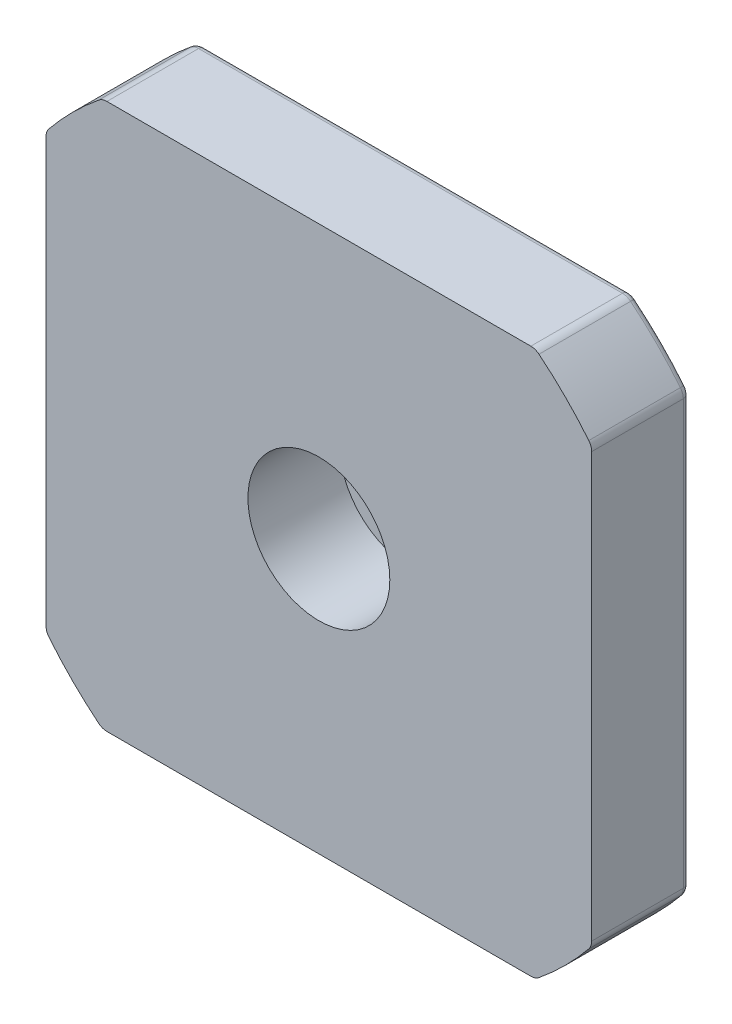
from build123d import *

# Parameters (mm, degrees)
CROQUIS1_W              = 42.3
CROQUIS1_H              = 42.3
SALIENTE_EXTRUIR1_DEPTH = 7.6
SKETCH1_R               = 29.910616844
SKETCH1_R_2             = 27
CUT_EXTRUDE1_DEPTH      = 8.6
CROQUIS3_R              = 11
CROQUIS3_R_2            = 8.5
SALIENTE_EXTRUIR2_DEPTH = 2
CROQUIS4_R              = 4.5
CORTAR_EXTRUIR2_DEPTH   = 7
CROQUIS5_R              = 2.5
CORTAR_EXTRUIR3_DEPTH   = 7
CROQUIS6_R              = 1.5
CORTAR_EXTRUIR4_DEPTH   = 4.5
SKETCH2_R               = 5.5
CUT_EXTRUDE2_DEPTH      = 7.1
SKETCH3_R               = 16.5
SKETCH3_R_2             = 11.5
CUT_EXTRUDE3_DEPTH      = 0.1
FILLET1_R               = 1
FILLET2_R               = 0.5
CHAMFER1_SIZE           = 0.5


with BuildPart() as part:
    # Croquis1 → Saliente-Extruir1 (new body)
    with BuildSketch(Plane.XY):
        Rectangle(CROQUIS1_W, CROQUIS1_H)
    extrude(amount=SALIENTE_EXTRUIR1_DEPTH)

    # Sketch1 → Cut-Extrude1 (cut, through all)
    with BuildSketch(Plane(origin=(0, 0, 0), x_dir=(-1, 0, 0), z_dir=(0, 0, -1))):
        Circle(SKETCH1_R)
        Circle(SKETCH1_R_2, mode=Mode.SUBTRACT)
    extrude(amount=-CUT_EXTRUDE1_DEPTH, mode=Mode.SUBTRACT)

    # Croquis3 → Saliente-Extruir2 (add)
    with BuildSketch(Plane(origin=(0, 0, 0), x_dir=(-1, 0, 0), z_dir=(0, 0, -1))):
        Circle(CROQUIS3_R)
        Circle(CROQUIS3_R_2, mode=Mode.SUBTRACT)
    extrude(amount=SALIENTE_EXTRUIR2_DEPTH)

    # Croquis4 → Cortar-Extruir2 (cut)
    with BuildSketch(Plane(origin=(0, 0, -2), x_dir=(-1, 0, 0), z_dir=(0, 0, -1))):
        Circle(CROQUIS4_R)
    extrude(amount=-CORTAR_EXTRUIR2_DEPTH, mode=Mode.SUBTRACT)

    # Croquis5 → Cortar-Extruir3 (cut)
    with BuildSketch(Plane(origin=(0, 0, 5), x_dir=(-1, 0, 0), z_dir=(0, 0, -1))):
        Circle(CROQUIS5_R)
    extrude(amount=-CORTAR_EXTRUIR3_DEPTH, mode=Mode.SUBTRACT)

    # Croquis6 → Cortar-Extruir4 (cut)
    with BuildSketch(Plane(origin=(0, 0, 0), x_dir=(-1, 0, 0), z_dir=(0, 0, -1))):
        with Locations((-15.5, 15.5)):
            Circle(CROQUIS6_R)
        with Locations((15.5, 15.5)):
            Circle(CROQUIS6_R)
        with Locations((15.5, -15.5)):
            Circle(CROQUIS6_R)
        with Locations((-15.5, -15.5)):
            Circle(CROQUIS6_R)
    extrude(amount=-CORTAR_EXTRUIR4_DEPTH, mode=Mode.SUBTRACT)

    # Sketch2 → Cut-Extrude2 (cut)
    with BuildSketch(Plane.XY.offset(7.6)):
        Circle(SKETCH2_R)
    extrude(amount=-CUT_EXTRUDE2_DEPTH, mode=Mode.SUBTRACT)

    # Sketch3 → Cut-Extrude3 (cut)
    with BuildSketch(Plane(origin=(0, 0, 0), x_dir=(-1, 0, 0), z_dir=(0, 0, -1))):
        Circle(SKETCH3_R)
        Circle(SKETCH3_R_2, mode=Mode.SUBTRACT)
    extrude(amount=-CUT_EXTRUDE3_DEPTH, mode=Mode.SUBTRACT)

    # Fillet1
    fillet1_edges = [part.edges().sort_by_distance(p)[0] for p in [
        (21.15, 16.783250579, 3.8),
        (21.15, -16.783250579, 3.8),
        (-16.783250579, 21.15, 3.8),
        (16.783250579, 21.15, 3.8),
        (-21.15, -16.783250579, 3.8),
        (-21.15, 16.783250579, 3.8),
        (16.783250579, -21.15, 3.8),
        (-16.783250579, -21.15, 3.8),
    ]]
    fillet(fillet1_edges, radius=FILLET1_R)

    # Fillet2
    fillet2_edges = [part.edges().sort_by_distance(p)[0] for p in [
        (19.091883092, 19.091883092, 0),
        (0, 21.15, 0),
        (-21.15, 0, 0),
        (-19.091883092, 19.091883092, 0),
        (21.15, 0, 0),
        (19.091883092, -19.091883092, 0),
        (0, -21.15, 0),
        (-19.091883092, -19.091883092, 0),
        (-16.766402254, 21.092072184, 0),
        (-21.092072184, 16.766402254, 0),
        (-21.092072184, -16.766402254, 0),
        (-16.766402254, -21.092072184, 0),
        (16.766402254, -21.092072184, 0),
        (21.092072184, -16.766402254, 0),
        (21.092072184, 16.766402254, 0),
        (16.766402254, 21.092072184, 0),
    ]]
    fillet(fillet2_edges, radius=FILLET2_R)

    # Chamfer1
    chamfer1_edges = [part.edges().sort_by_distance(p)[0] for p in [
        (11, 0, -2),
    ]]
    chamfer(chamfer1_edges, length=CHAMFER1_SIZE)


solid = part.part
